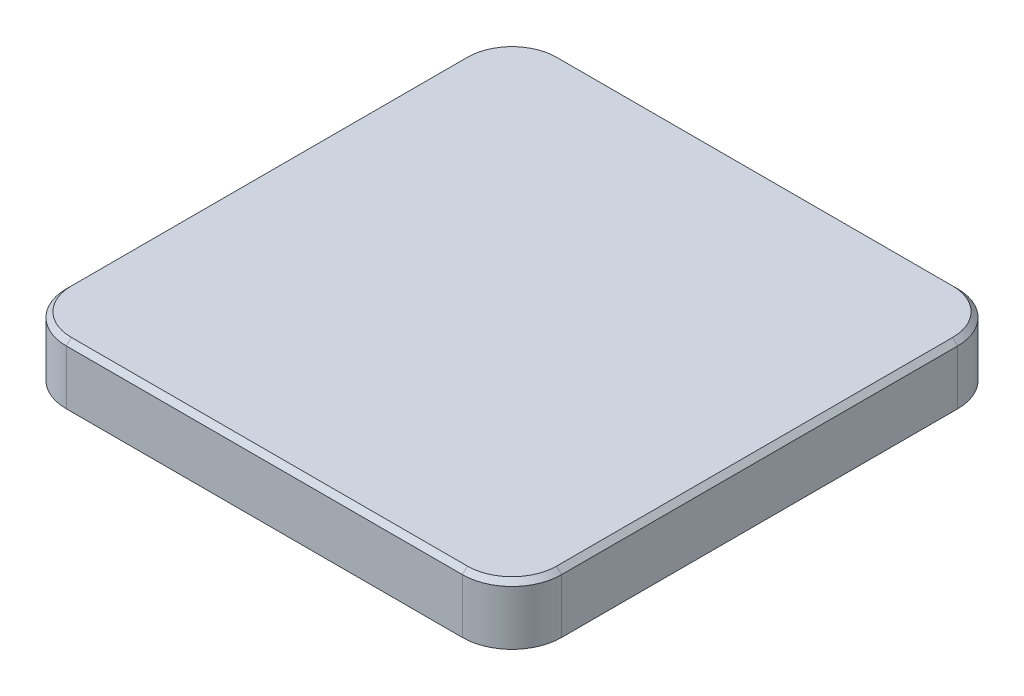
from build123d import *

# Parameters (mm, degrees)
BOSS_EXTRUDE1_DEPTH = 6
CHAMFER1_SIZE       = 1


with BuildPart() as part:
    # Sketch1 → Boss-Extrude1 (new body, symmetric)
    with BuildSketch(Plane(origin=(0, 0, 0), x_dir=(1, 0, 0), z_dir=(0, 1, 0))):
        with BuildLine():
            Line((-40, -50), (40, -50))
            ThreePointArc((40, -50), (47.071067812, -47.071067812), (50, -40))
            Line((50, -40), (50, 40))
            ThreePointArc((50, 40), (47.071067812, 47.071067812), (40, 50))
            Line((40, 50), (-40, 50))
            ThreePointArc((-40, 50), (-47.071067812, 47.071067812), (-50, 40))
            Line((-50, 40), (-50, -40))
            ThreePointArc((-50, -40), (-47.071067812, -47.071067812), (-40, -50))
        make_face()
    extrude(amount=BOSS_EXTRUDE1_DEPTH, both=True)

    # Chamfer1
    chamfer1_edges = [part.edges().sort_by_distance(p)[0] for p in [
        (47.071067812, 6, 47.071067812),
        (50, 6, 0),
        (47.071067812, 6, -47.071067812),
        (0, 6, -50),
        (-47.071067812, 6, -47.071067812),
        (-50, 6, 0),
        (-47.071067812, 6, 47.071067812),
        (0, 6, 50),
    ]]
    chamfer(chamfer1_edges, length=CHAMFER1_SIZE)


solid = part.part
